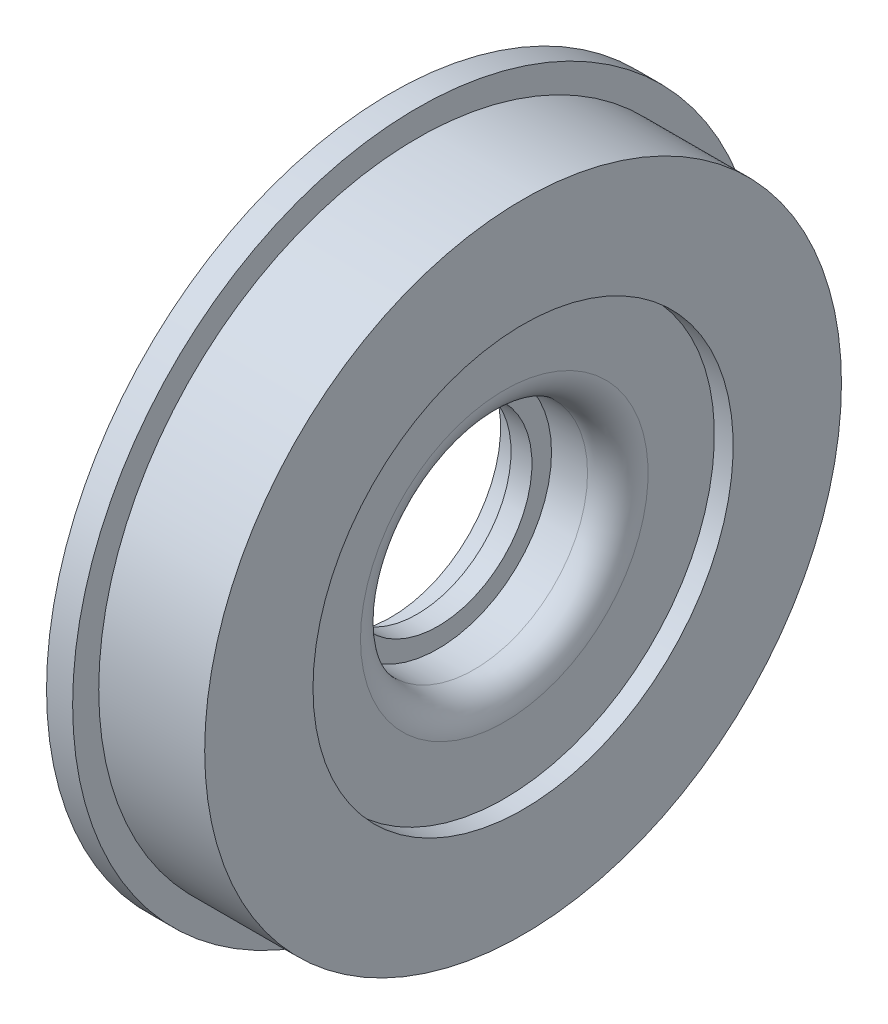
from build123d import *


with BuildPart() as part:
    # Sketch1 → Body (revolve)
    with BuildSketch(Plane.XY):
        with BuildLine():
            Line((0, 21), (5, 21))
            Line((5, 21), (5, 18))
            Line((5, 18), (9, 18))
            Line((9, 18), (9, 21.75))
            Line((9, 21.75), (15.9, 21.75))
            ThreePointArc((15.9, 21.75), (20.001219331, 23.448780669), (21.7, 27.55))
            Line((21.7, 27.55), (21.7, 40.25))
            Line((21.7, 40.25), (25.3, 40.25))
            Line((25.3, 40.25), (25.3, 61))
            Line((25.3, 61), (5, 61))
            Line((5, 61), (5, 66))
            Line((5, 66), (0, 66))
            Line((0, 66), (0, 21))
        make_face()
    revolve(axis=Axis((0, 0, 0), (1, 0, 0)))


solid = part.part
